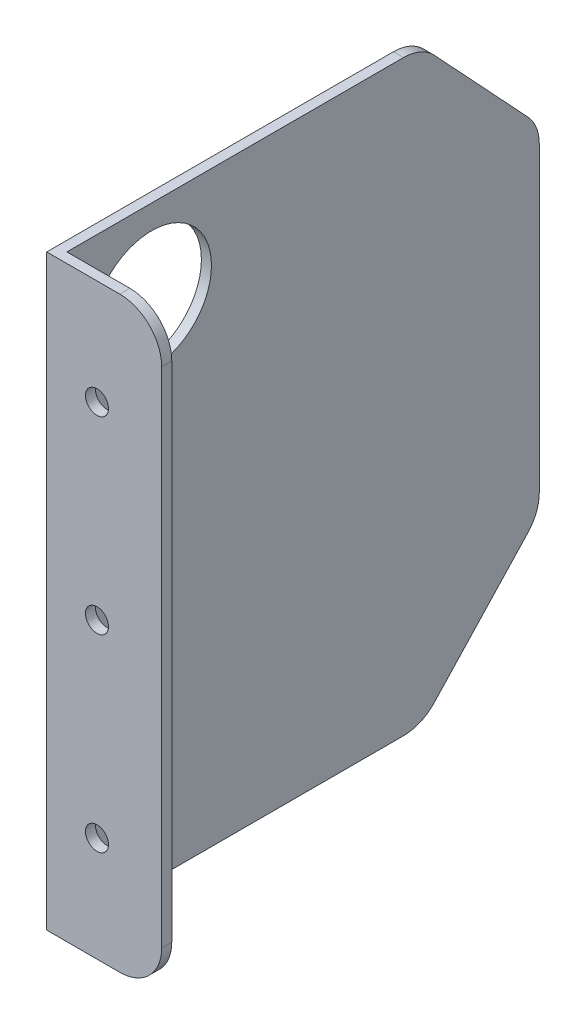
from build123d import *

# Parameters (mm, degrees)
SKETCH1_W           = 115
SKETCH1_H           = 140
BOSS_EXTRUDE1_DEPTH = 2.4
CUT_EXTRUDE1_DEPTH  = 3.4
FILLET1_R           = 10
SKETCH3_W           = 2.4
SKETCH3_H           = 140
BOSS_EXTRUDE2_DEPTH = 25
FILLET2_R           = 10
SKETCH4_R           = 2.75
CUT_EXTRUDE2_DEPTH  = 116
SKETCH5_R           = 14.275
CUT_EXTRUDE3_DEPTH  = 3.4


with BuildPart() as part:
    # Sketch1 → Boss-Extrude1 (new body)
    with BuildSketch(Plane(origin=(0, 0, 0), x_dir=(0, 0, -1), z_dir=(1, 0, 0))):
        with Locations((57.5, -70)):
            Rectangle(SKETCH1_W, SKETCH1_H)
    extrude(amount=BOSS_EXTRUDE1_DEPTH)

    # Sketch2 → Cut-Extrude1 (cut, through all)
    with BuildSketch(Plane(origin=(2.4, 0, 0), x_dir=(0, 0, -1), z_dir=(1, 0, 0))):
        Polygon((87, 0), (115, -30), (142.616199658, -32.505405645), (142.616199658, 14.875556406), align=None)
        Polygon((115, -110), (87, -140), (87, -152.661109726), (136.310004643, -152.661109726), align=None)
    extrude(amount=-CUT_EXTRUDE1_DEPTH, mode=Mode.SUBTRACT)

    # Fillet1
    fillet1_edges = [part.edges().sort_by_distance(p)[0] for p in [
        (1.2, 0, -87),
        (1.2, -30, -115),
        (1.2, -110, -115),
        (1.2, -140, -87),
    ]]
    fillet(fillet1_edges, radius=FILLET1_R)

    # Sketch3 → Boss-Extrude2 (add)
    with BuildSketch(Plane(origin=(2.4, 0, 0), x_dir=(0, 0, -1), z_dir=(1, 0, 0))):
        with Locations((1.2, -70)):
            Rectangle(SKETCH3_W, SKETCH3_H)
    extrude(amount=BOSS_EXTRUDE2_DEPTH)

    # Fillet2
    fillet2_edges = [part.edges().sort_by_distance(p)[0] for p in [
        (27.4, -140, -1.2),
        (27.4, 0, -1.2),
    ]]
    fillet(fillet2_edges, radius=FILLET2_R)

    # Sketch4 → Cut-Extrude2 (cut, through all)
    with BuildSketch(Plane.XY):
        with Locations((11.974983581, -70)):
            Circle(SKETCH4_R)
        with Locations((11.974983581, -25)):
            Circle(SKETCH4_R)
        with Locations((11.974983581, -115)):
            Circle(SKETCH4_R)
    extrude(amount=-CUT_EXTRUDE2_DEPTH, mode=Mode.SUBTRACT)

    # Sketch5 → Cut-Extrude3 (cut, through all)
    with BuildSketch(Plane(origin=(2.4, 0, 0), x_dir=(0, 0, -1), z_dir=(1, 0, 0))):
        with Locations((22.591699334, -20)):
            Circle(SKETCH5_R)
    extrude(amount=-CUT_EXTRUDE3_DEPTH, mode=Mode.SUBTRACT)


solid = part.part
